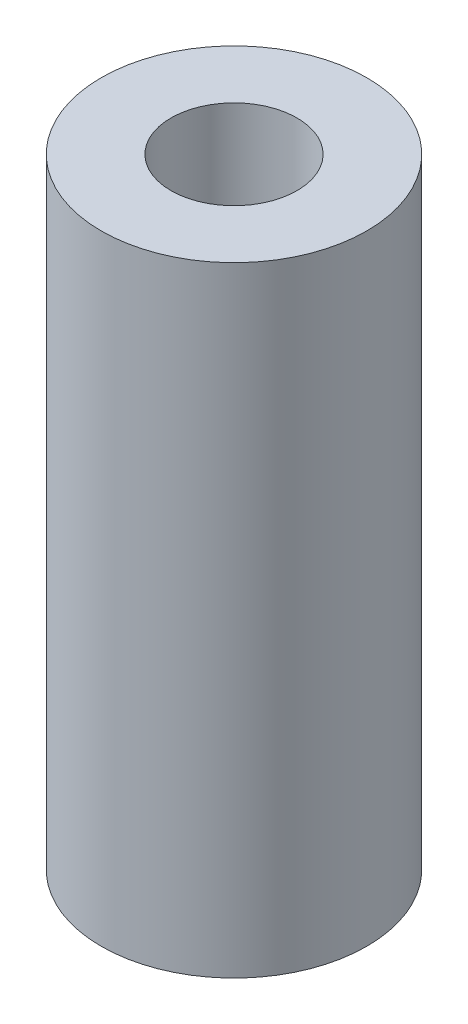
from build123d import *

# Parameters (mm, degrees)
SKETCH1_R                     = 2.38125
BOSS_EXTRUDE1_DEPTH           = 11.1125
TAP_DRILL_FOR_4_40_TAP1_D     = 2.2606
TAP_DRILL_FOR_4_40_TAP1_DEPTH = 11.1125


with BuildPart() as part:
    # Sketch1 → Boss-Extrude1 (new body)
    with BuildSketch(Plane(origin=(0, 0, 0), x_dir=(1, 0, 0), z_dir=(0, 1, 0))):
        Circle(SKETCH1_R)
    extrude(amount=BOSS_EXTRUDE1_DEPTH)

    # Tap Drill for #4-40 Tap1
    with Locations(Plane(origin=(0, 11.1125, 0), x_dir=(-1, 0, 0), z_dir=(0, 1, 0))):
        with Locations((0, 0)):
            Hole(TAP_DRILL_FOR_4_40_TAP1_D / 2, depth=TAP_DRILL_FOR_4_40_TAP1_DEPTH)


solid = part.part
